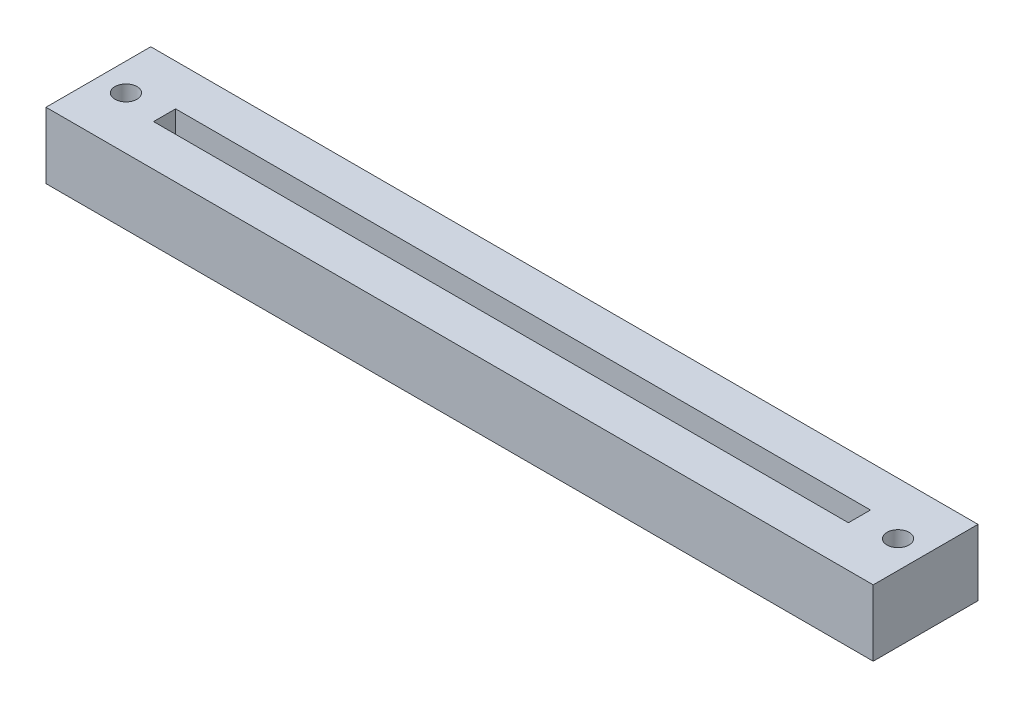
from build123d import *

# Parameters (mm, degrees)
SKETCH1_W           = 75
SKETCH1_H           = 9.5
BOSS_EXTRUDE1_DEPTH = 6
SKETCH2_R           = 1
SKETCH2_W           = 63
SKETCH2_H           = 2
CUT_EXTRUDE1_DEPTH  = 3


with BuildPart() as part:
    # Sketch1 → Boss-Extrude1 (new body)
    with BuildSketch(Plane(origin=(0, 0, 0), x_dir=(1, 0, 0), z_dir=(0, 1, 0))):
        with Locations((37.5, 4.75)):
            Rectangle(SKETCH1_W, SKETCH1_H)
    extrude(amount=BOSS_EXTRUDE1_DEPTH)

    # Sketch2 → Cut-Extrude1 (cut)
    with BuildSketch(Plane(origin=(0, 6, 0), x_dir=(1, 0, 0), z_dir=(0, 1, 0))):
        with Locations((2.5, 4.75)):
            Circle(SKETCH2_R)
        with Locations((72.5, 4.75)):
            Circle(SKETCH2_R)
        with Locations((37.5, 4.75)):
            Rectangle(SKETCH2_W, SKETCH2_H)
    extrude(amount=-CUT_EXTRUDE1_DEPTH, mode=Mode.SUBTRACT)


solid = part.part
